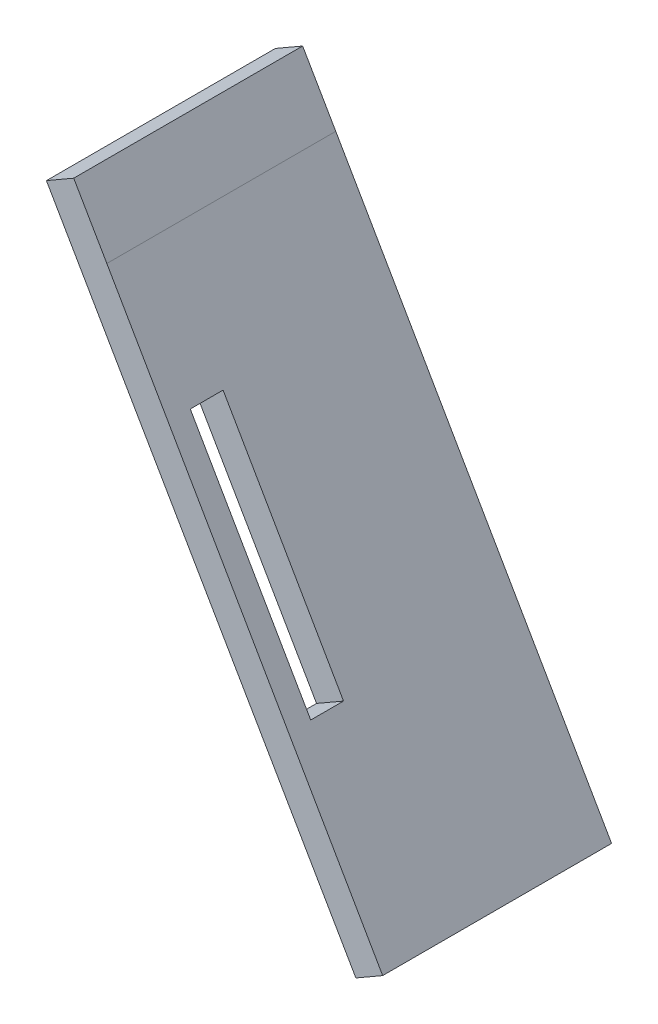
from build123d import *

# Parameters (mm, degrees)
SALIENTE_EXTRUIR1_DEPTH = 37
CORTAR_EXTRUIR1_DEPTH   = 10


with BuildPart() as part:
    # Croquis1 → Saliente-Extruir1 (new body)
    with BuildSketch(Plane.XY):
        Polygon((55.350000047, 77.336068513), (100.017938292, 0), (104.347630379, 2.500753173), (59.766286021, 79.886836776), (54.412620908, 89.152214546), (50.000000028, 86.602540366), align=None)
    extrude(amount=SALIENTE_EXTRUIR1_DEPTH)

    # Croquis2 → Cortar-Extruir1 (cut)
    with BuildSketch(Plane(origin=(79.427815776, 45.757565725, 0), x_dir=(0, 0, -1), z_dir=(0.866497897, 0.499180723, 0))):
        Polygon((-33.424409531, 19.532383801), (-33.424409531, -19.467616199), (-28.124409531, -19.467616199), (-28.124409531, -0.028001757), (-28.124409531, 0.092769359), (-28.124409531, 19.532383801), align=None)
    extrude(amount=-CORTAR_EXTRUIR1_DEPTH, mode=Mode.SUBTRACT)


solid = part.part
